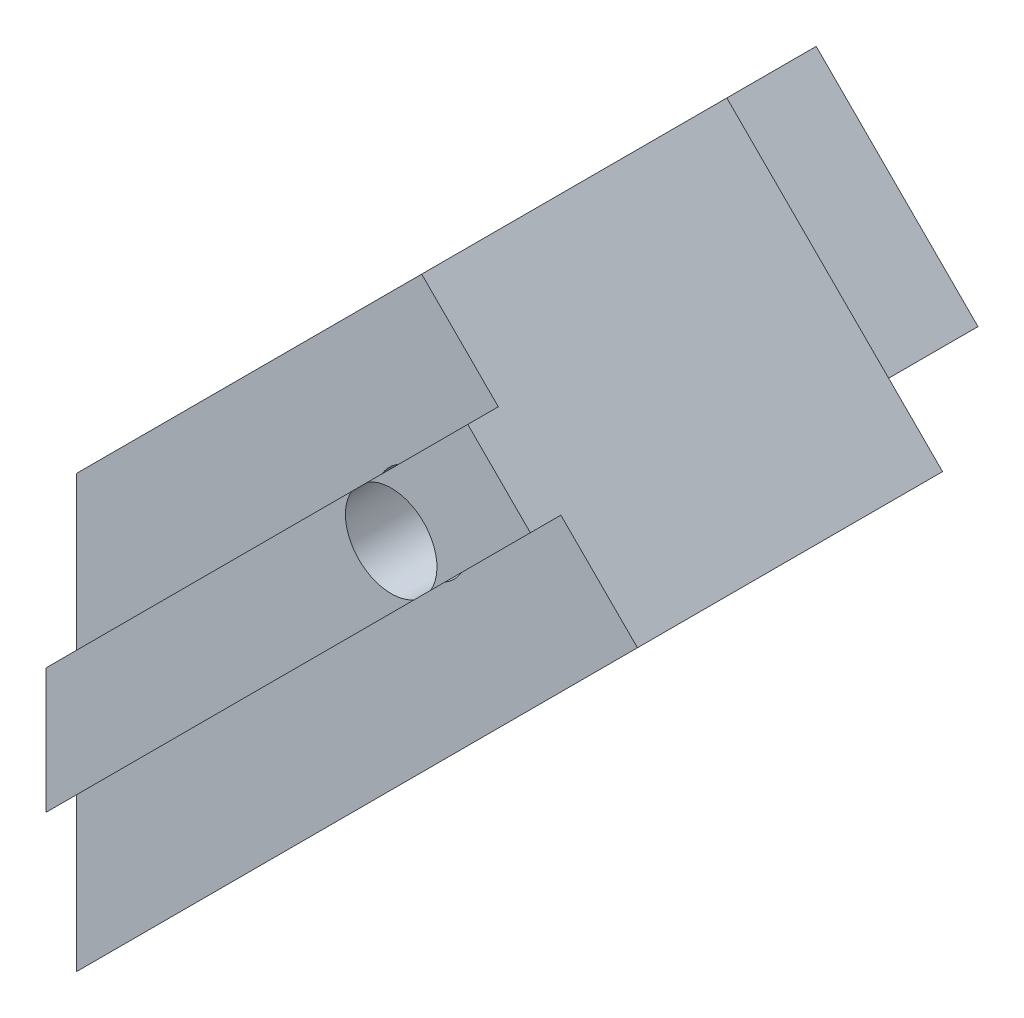
from build123d import *

# Parameters (mm, degrees)
BOSS_EXTRU_1_DEPTH       = 20
ESQUISSE2_W              = 10
ESQUISSE2_H              = 21
ENL_V_MAT_EXTRU_1_DEPTH  = 2.5
ESQUISSE3_R              = 1.5
ENL_V_MAT_EXTRU_2_DEPTH  = 20.384776311
ESQUISSE4_R              = 4.1
ENL_V_MAT_EXTRU_3_DEPTH  = 16.384776311
ESQUISSE5_R              = 1.25
ENL_V_MAT_EXTRU_4_DEPTH  = 17.207106781
BOSS_EXTRU_2_DEPTH       = 1
ENL_V_MAT_EXTRU_7_DEPTH  = 11
ENL_V_MAT_EXTRU_8_DEPTH  = 11
ESQUISSE11_R             = 1.5
ENL_V_MAT_EXTRU_9_DEPTH  = 12
ESQUISSE12_R             = 4.1
ENL_V_MAT_EXTRU_10_DEPTH = 7.5


with BuildPart() as part:
    # Esquisse1 → Boss.-Extru.1 (new body)
    with BuildSketch(Plane.XY):
        Polygon((0, 0), (0, 5), (-1, 5), (-1, 7.9), (0, 7.9), (0, 14.142135624), (11.313708499, 25.455844123), (18.384776311, 18.384776311), align=None)
    extrude(amount=BOSS_EXTRU_1_DEPTH)

    # Esquisse2 → Enlèv. mat.-Extru.1 (cut)
    with BuildSketch(Plane(origin=(0, 0, 0), x_dir=(0, 0, -1), z_dir=(0.707106781, -0.707106781, 0))):
        with Locations((-5, 15.5)):
            Rectangle(ESQUISSE2_W, ESQUISSE2_H)
    extrude(amount=-ENL_V_MAT_EXTRU_1_DEPTH, mode=Mode.SUBTRACT)

    # Esquisse3 → Enlèv. mat.-Extru.2 (cut, through all)
    with BuildSketch(Plane.ZY.offset(1)):
        with Locations((15, 6.45)):
            Circle(ESQUISSE3_R)
    extrude(amount=-ENL_V_MAT_EXTRU_2_DEPTH, mode=Mode.SUBTRACT)

    # Esquisse4 → Enlèv. mat.-Extru.3 (cut, through all)
    with BuildSketch(Plane.ZY.offset(-3)):
        with Locations((15, 6.45)):
            Circle(ESQUISSE4_R)
    extrude(amount=-ENL_V_MAT_EXTRU_3_DEPTH, mode=Mode.SUBTRACT)

    # Esquisse5 → Enlèv. mat.-Extru.4 (cut, through all)
    with BuildSketch(Plane(origin=(-1.767766953, 1.767766953, 0), x_dir=(0, 0, -1), z_dir=(0.707106781, -0.707106781, 0))):
        with Locations((-5, 11.5)):
            Circle(ESQUISSE5_R)
    extrude(amount=-ENL_V_MAT_EXTRU_4_DEPTH, mode=Mode.SUBTRACT)

    # Esquisse6 → Boss.-Extru.2 (add)
    with BuildSketch(Plane.XY.offset(20)):
        Polygon((0, 9.121677477), (13.823937572, 22.94561505), (15.874547238, 20.895005384), (0, 5.020458146), align=None)
    extrude(amount=BOSS_EXTRU_2_DEPTH)

    # Esquisse9 → Enlèv. mat.-Extru.7 (cut, through all)
    with BuildSketch(Plane(origin=(0, 0, 10), x_dir=(-1, 0, 0), z_dir=(0, 0, -1))):
        Polygon((-18.384776311, 18.384776311), (-12.02081528, 12.02081528), (-4.949747468, 19.091883092), (-11.313708499, 25.455844123), align=None)
    extrude(amount=ENL_V_MAT_EXTRU_7_DEPTH, mode=Mode.SUBTRACT)

    # Esquisse10 → Enlèv. mat.-Extru.8 (cut, through all)
    with BuildSketch(Plane(origin=(0, 0, 10), x_dir=(-1, 0, 0), z_dir=(0, 0, -1))):
        Polygon((-11.313708499, 25.455844123), (-4.242640687, 18.384776311), (-11.313708499, 11.313708499), (-18.384776311, 18.384776311), align=None)
    extrude(amount=ENL_V_MAT_EXTRU_8_DEPTH, mode=Mode.SUBTRACT)

    # Esquisse11 → Enlèv. mat.-Extru.9 (cut, through all)
    with BuildSketch(Plane(origin=(0, 0, 10), x_dir=(-1, 0, 0), z_dir=(0, 0, -1))):
        with Locations((-11.313708499, 18.384776311)):
            Circle(ESQUISSE11_R)
    extrude(amount=-ENL_V_MAT_EXTRU_9_DEPTH, mode=Mode.SUBTRACT)

    # Esquisse12 → Enlèv. mat.-Extru.10 (cut)
    with BuildSketch(Plane(origin=(0, 0, 10), x_dir=(-1, 0, 0), z_dir=(0, 0, -1))):
        with Locations((-11.313708499, 18.384776311)):
            Circle(ESQUISSE12_R)
    extrude(amount=-ENL_V_MAT_EXTRU_10_DEPTH, mode=Mode.SUBTRACT)


solid = part.part
